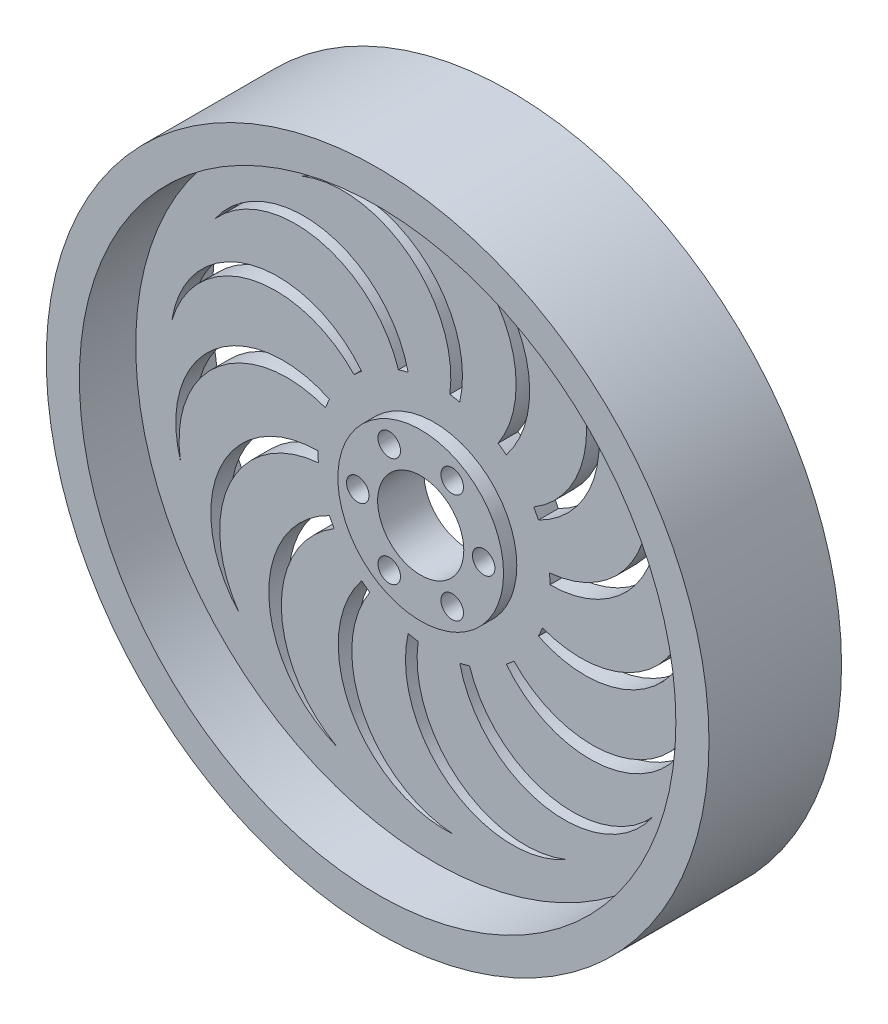
from build123d import *

# Parameters (mm, degrees)
SKETCH1_W            = 32.5
SKETCH1_H            = 3
SKETCH1_W_2          = 6
SKETCH1_H_2          = 7
M3_CLEARANCE_HOLE1_D = 3.4
CUT_EXTRUDE1_DEPTH   = 12.5
CIRPATTERN1_COUNT    = 14


with BuildPart() as part:
    # Sketch1 → Revolve1 (revolve)
    with BuildSketch(Plane(origin=(0, 0, 0), x_dir=(1, 0, 0), z_dir=(0, 1, 0))):
        Polygon((45, 1.5), (45, -1.5), (45, -10), (50, -10), (50, 10), (45, 10), align=None)
        with Locations((28.75, 0)):
            Rectangle(SKETCH1_W, SKETCH1_H)
        with Locations((9.5, 0)):
            Rectangle(SKETCH1_W_2, SKETCH1_H_2)
    revolve(axis=Axis((0, 0, 77.742212382), (0, 0, -1)))

    # M3 Clearance Hole1 (through all)
    with Locations(Plane.XY.offset(3.5)):
        with Locations((-4.75, 8.227241336), (4.75, 8.227241336), (9.5, 0), (4.75, -8.227241336), (-4.75, -8.227241336), (-9.5, 0)):
            Hole(M3_CLEARANCE_HOLE1_D / 2)

    # Sketch5 → Cut-Extrude1 (cut, through all)
    with BuildSketch(Plane.XY.offset(1.5)):
        with BuildLine():
            ThreePointArc((17.433407217, 1.525225498), (17.483343878, 0.763339279), (17.5, 0))
            ThreePointArc((17.5, 0), (32.3159819, 9.689882919), (29.37704918, 27.147540984))
            ThreePointArc((29.37704918, 27.147540984), (30.802914583, 10.888009592), (17.433407217, 1.525225498))
        make_face()
    cut_extrude1 = extrude(amount=-CUT_EXTRUDE1_DEPTH, mode=Mode.SUBTRACT)

    # CirPattern1: Cut-Extrude1 ×14 about axis
    cirpattern1_axis = Axis((0, 0, 0), (0, 0, 1))
    for i in range(1, CIRPATTERN1_COUNT):
        add(cut_extrude1.rotate(cirpattern1_axis, i * 360 / CIRPATTERN1_COUNT), mode=Mode.SUBTRACT)


solid = part.part
